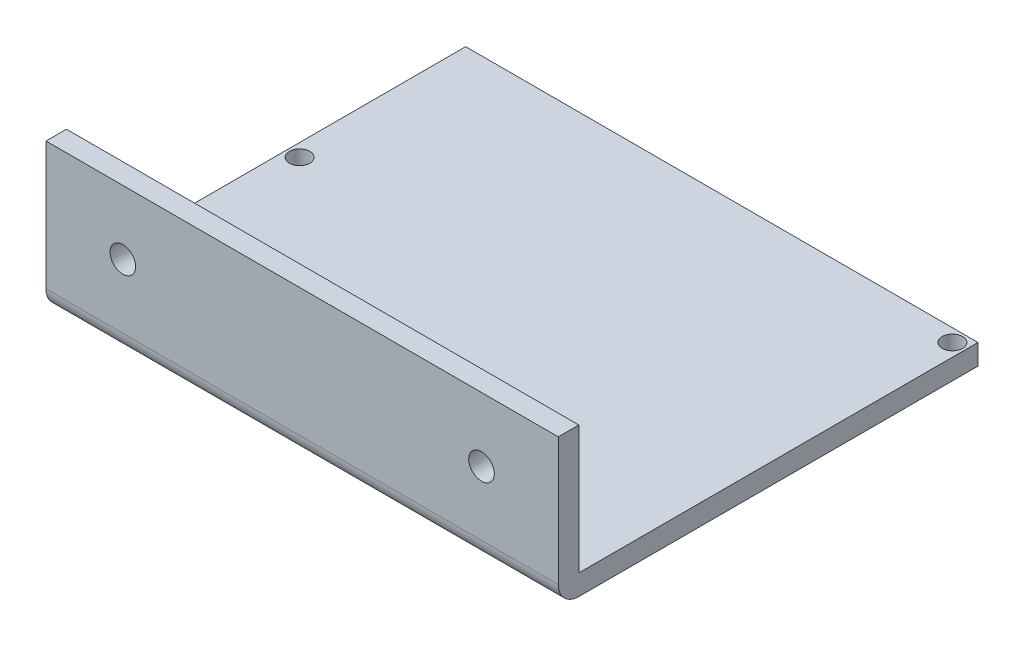
from build123d import *

# Parameters (mm, degrees)
SKETCH1_W           = 100
SKETCH1_H           = 72.907808631
SKETCH1_R           = 2
SKETCH1_R_2         = 2.083080247
BOSS_EXTRUDE1_DEPTH = 4
BOSS_EXTRUDE2_DEPTH = 100
SKETCH3_R           = 2.5
CUT_EXTRUDE1_DEPTH  = 4
SKETCH4_W           = 54.032487287
SKETCH4_H           = 4.238299892
SKETCH4_W_2         = 12.902793756
CUT_EXTRUDE4_DEPTH  = 2


with BuildPart() as part:
    # Sketch1 → Boss-Extrude1 (new body)
    with BuildSketch(Plane(origin=(0, 0, 0), x_dir=(1, 0, 0), z_dir=(0, 1, 0))):
        with Locations((50, 36.453904316)):
            Rectangle(SKETCH1_W, SKETCH1_H)
        with Locations((97.5, 70.407808631)):
            Circle(SKETCH1_R, mode=Mode.SUBTRACT)
        with Locations((2.5, 38)):
            Circle(SKETCH1_R, mode=Mode.SUBTRACT)
        with Locations((82.5, 3.5)):
            Circle(SKETCH1_R, mode=Mode.SUBTRACT)
        with Locations((20, 3.5)):
            Circle(SKETCH1_R_2, mode=Mode.SUBTRACT)
    extrude(amount=BOSS_EXTRUDE1_DEPTH)

    # Sketch2 → Boss-Extrude2 (add)
    with BuildSketch(Plane.ZY):
        with BuildLine():
            Line((0, 4), (5, 4))
            Line((5, 4), (5, 29))
            Line((5, 29), (9, 29))
            Line((9, 29), (9, 5.38521522))
            Line((9, 5.38521522), (9, 4))
            ThreePointArc((9, 4), (7.828427125, 1.171572875), (5, 0))
            Line((5, 0), (0, 0))
            Line((0, 0), (0, 4))
        make_face()
    extrude(amount=-BOSS_EXTRUDE2_DEPTH)

    # Sketch3 → Cut-Extrude1 (cut)
    with BuildSketch(Plane.XY.offset(9)):
        with Locations((15, 16.5)):
            Circle(SKETCH3_R)
        with Locations((85, 16.5)):
            Circle(SKETCH3_R)
    extrude(amount=-CUT_EXTRUDE1_DEPTH, mode=Mode.SUBTRACT)

    # Sketch4 → Cut-Extrude4 (cut)
    with BuildSketch(Plane.XZ):
        Polygon((51.950078291, -63.631079916), (12.647642859, -63.631079916), (12.647642859, -44.280868197), (3.432980611, -44.280868197), (3.432980611, -70.907808631), (12.647642859, -70.907808631), (91.252513722, -70.907808631), (97.892827947, -63.631079916), (97.892827947, -36.415165299), (91.252513722, -36.415165299), (91.252513722, -63.631079916), (61.978819372, -63.631079916), (61.978819372, -54.74747752), (51.950078291, -54.74747752), align=None)
        with Locations((51.441944052, -3.540646856)):
            Rectangle(SKETCH4_W, SKETCH4_H)
        with Locations((9.884377489, -3.540646856)):
            Rectangle(SKETCH4_W_2, SKETCH4_H)
    extrude(amount=-CUT_EXTRUDE4_DEPTH, mode=Mode.SUBTRACT)


solid = part.part
